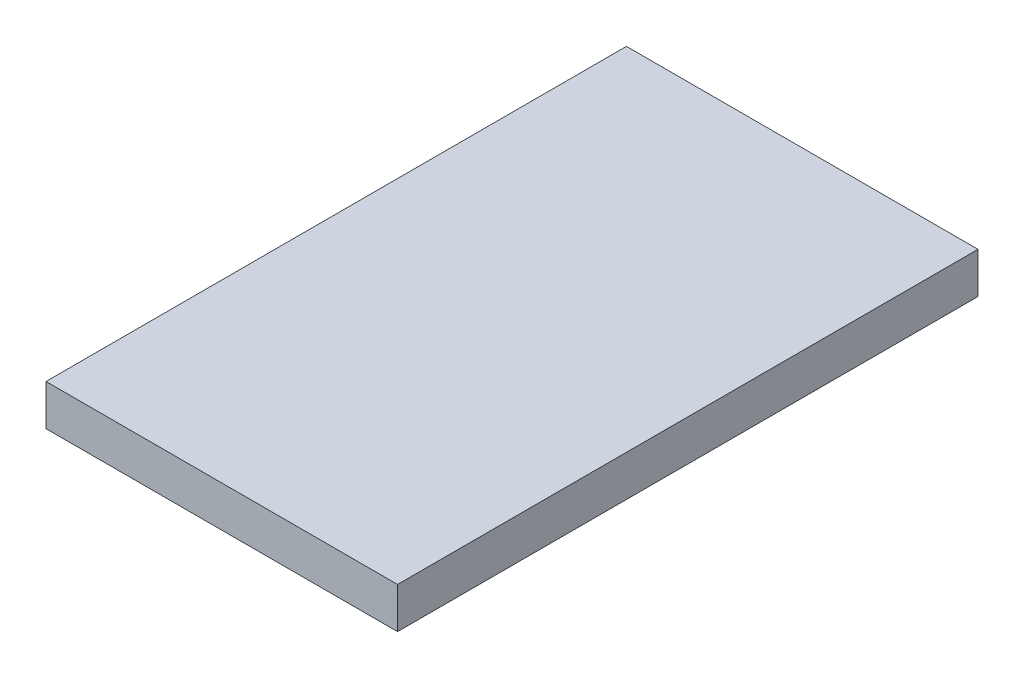
from build123d import *

# Parameters (mm, degrees)
SKETCH1_W           = 54.61
SKETCH1_H           = 90.17
BOSS_EXTRUDE1_DEPTH = 6.35
SKETCH3_W           = 54.61
SKETCH3_H           = 6.35
BOSS_EXTRUDE2_DEPTH = 90.17


with BuildPart() as part:
    # Sketch1 → Boss-Extrude1 (new body)
    with BuildSketch(Plane(origin=(0, 0, 0), x_dir=(1, 0, 0), z_dir=(0, 1, 0))):
        with Locations((-27.305, 45.085)):
            Rectangle(SKETCH1_W, SKETCH1_H)
    extrude(amount=BOSS_EXTRUDE1_DEPTH)

    # Sketch3 → Boss-Extrude2 (add)
    with BuildSketch(Plane.XY):
        with Locations((-27.305, 3.175)):
            Rectangle(SKETCH3_W, SKETCH3_H)
    extrude(amount=-BOSS_EXTRUDE2_DEPTH)


solid = part.part
